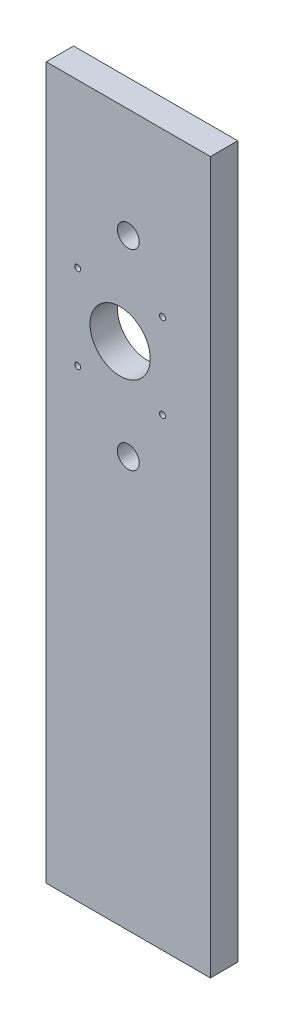
from build123d import *

# Parameters (mm, degrees)
CROQUIS1_W              = 60
CROQUIS1_H              = 260
CROQUIS1_R              = 11
CROQUIS1_R_2            = 4
CROQUIS1_R_3            = 1.09
SALIENTE_EXTRUIR1_DEPTH = 10


with BuildPart() as part:
    # Croquis1 → Saliente-Extruir1 (new body)
    with BuildSketch(Plane.XY):
        Rectangle(CROQUIS1_W, CROQUIS1_H)
        with Locations((-3, 55)):
            Circle(CROQUIS1_R, mode=Mode.SUBTRACT)
        with Locations((0, 90)):
            Circle(CROQUIS1_R_2, mode=Mode.SUBTRACT)
        with Locations((0, 20)):
            Circle(CROQUIS1_R_2, mode=Mode.SUBTRACT)
        with Locations((-18.5, 70.5)):
            Circle(CROQUIS1_R_3, mode=Mode.SUBTRACT)
        with Locations((12.5, 70.5)):
            Circle(CROQUIS1_R_3, mode=Mode.SUBTRACT)
        with Locations((12.5, 39.5)):
            Circle(CROQUIS1_R_3, mode=Mode.SUBTRACT)
        with Locations((-18.5, 39.5)):
            Circle(CROQUIS1_R_3, mode=Mode.SUBTRACT)
    extrude(amount=SALIENTE_EXTRUIR1_DEPTH)


solid = part.part
